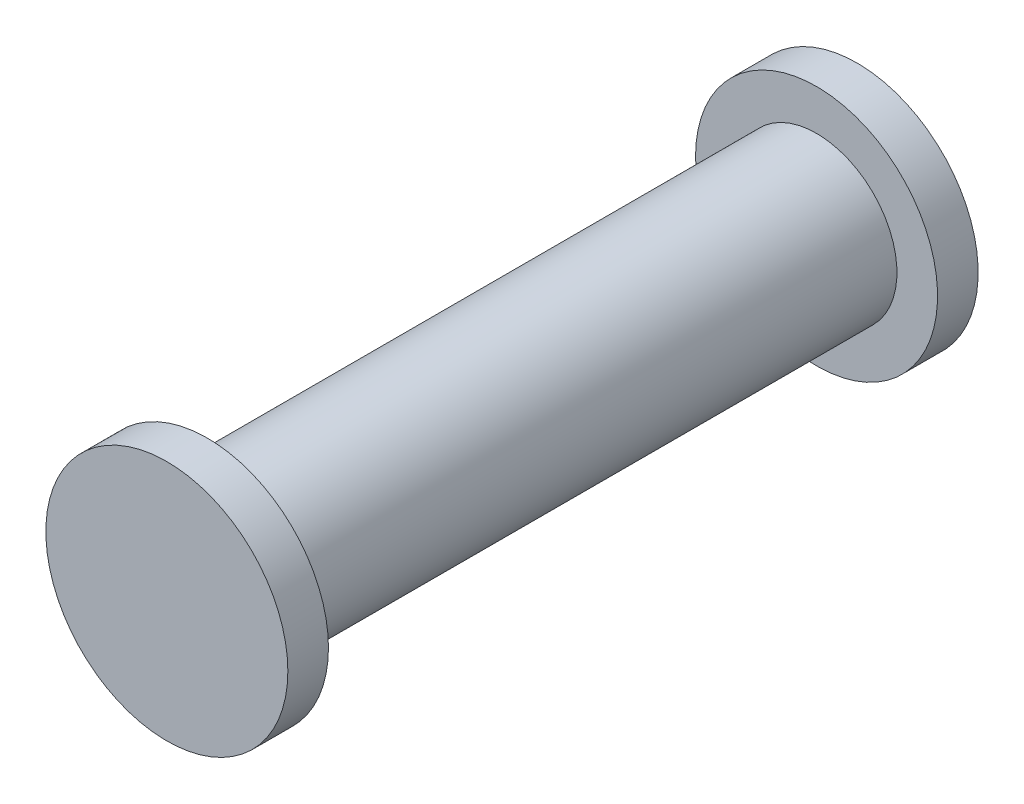
from build123d import *

# Parameters (mm, degrees)
SKETCH1_R           = 4.95
BOSS_EXTRUDE1_DEPTH = 37.5
SKETCH2_R           = 7.45
BOSS_EXTRUDE2_DEPTH = 2.5
SKETCH3_R           = 7.45
BOSS_EXTRUDE3_DEPTH = 2.5


with BuildPart() as part:
    # Sketch1 → Boss-Extrude1 (new body)
    with BuildSketch(Plane.XY):
        Circle(SKETCH1_R)
    extrude(amount=BOSS_EXTRUDE1_DEPTH)

    # Sketch2 → Boss-Extrude2 (add)
    with BuildSketch(Plane(origin=(0, 0, 0), x_dir=(-1, 0, 0), z_dir=(0, 0, -1))):
        Circle(SKETCH2_R)
    extrude(amount=BOSS_EXTRUDE2_DEPTH)

    # Sketch3 → Boss-Extrude3 (add)
    with BuildSketch(Plane.XY.offset(37.5)):
        Circle(SKETCH3_R)
    extrude(amount=BOSS_EXTRUDE3_DEPTH)


solid = part.part
